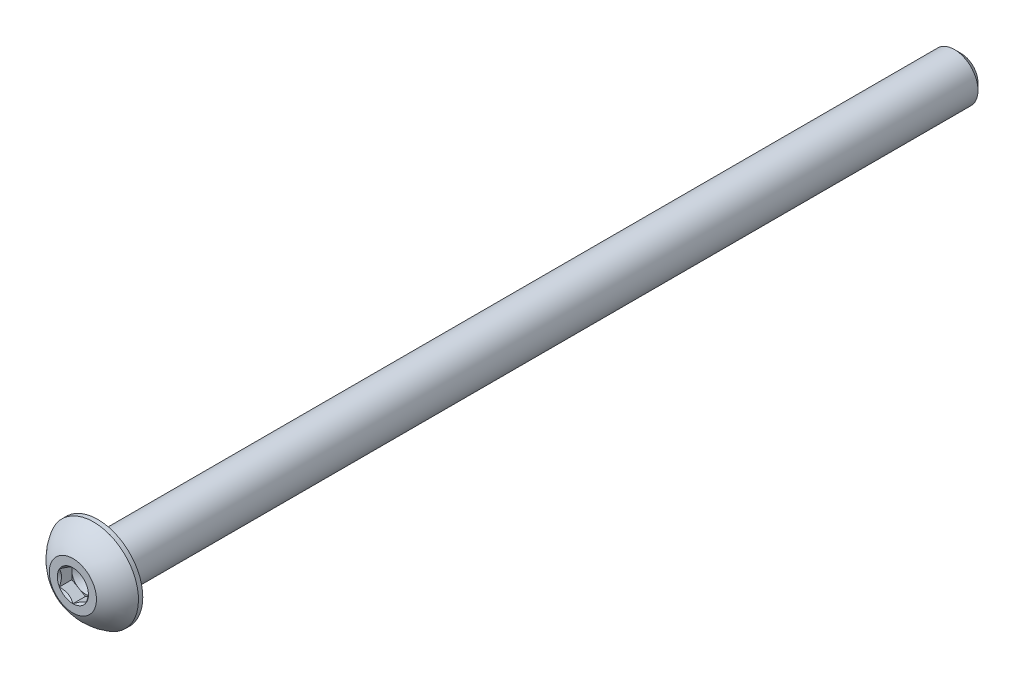
from build123d import *

# Parameters (mm, degrees)
SKETCH1_W          = 76.2
SKETCH1_H          = 2.0828
CHAMFER1_SIZE      = 0.5953125
SKETCH4_R          = 3.9624
EXTRUDE1_DEPTH     = 2.2098
CUT_EXTRUDE1_DEPTH = 1.1049
SKETCH7_R          = 1.374815329
CUT_EXTRUDE4_DEPTH = 1.1049
CUT_EXTRUDE4_TAPER = 45
SKETCH8_R          = 1.190625
CUT_EXTRUDE5_DEPTH = 0.3683
CUT_EXTRUDE5_TAPER = 60


with BuildPart() as part:
    # Sketch1 → Revolve1 (revolve)
    with BuildSketch(Plane(origin=(0, 0, 0), x_dir=(0, 0, -1), z_dir=(1, 0, 0))):
        with Locations((38.1, 1.0414)):
            Rectangle(SKETCH1_W, SKETCH1_H)
    revolve(axis=Axis((0, 0, 0), (0, 0, 1)))

    # Chamfer1
    chamfer1_edges = [part.edges().sort_by_distance(p)[0] for p in [
        (0, -2.0828, -76.2),
    ]]
    chamfer(chamfer1_edges, length=CHAMFER1_SIZE)

    # Sketch4 → Extrude1 (add)
    with BuildSketch(Plane.XY):
        Circle(SKETCH4_R)
    extrude(amount=EXTRUDE1_DEPTH)

    # Sketch9 → Cut-Revolve3 (revolve, cut)
    with BuildSketch(Plane(origin=(0, 0, 0), x_dir=(0, 0, -1), z_dir=(1, 0, 0))):
        with BuildLine():
            Line((0, 3.9624), (-0.381, 3.9624))
            ThreePointArc((-0.381, 3.9624), (-1.434442989, 3.157885071), (-2.2098, 2.0828))
            Line((-2.2098, 2.0828), (-2.5908, 2.0828))
            Line((-2.5908, 2.0828), (-2.5908, 4.3434))
            Line((-2.5908, 4.3434), (0, 4.3434))
            Line((0, 4.3434), (0, 3.9624))
        make_face()
    revolve(axis=Axis((0, 0, 0), (0, 0, 1)), mode=Mode.SUBTRACT)

    # Sketch6 → Cut-Extrude1 (cut)
    with BuildSketch(Plane.XY.offset(2.2098)):
        Polygon((0, -1.374815329), (1.190625, -0.687407664), (1.190625, 0.687407664), (0, 1.374815329), (-1.190625, 0.687407664), (-1.190625, -0.687407664), align=None)
    extrude(amount=-CUT_EXTRUDE1_DEPTH, mode=Mode.SUBTRACT)

    # Sketch7 → Cut-Extrude4 (cut)
    with BuildSketch(Plane.XY.offset(2.2098)):
        Circle(SKETCH7_R)
    extrude(amount=-CUT_EXTRUDE4_DEPTH, taper=CUT_EXTRUDE4_TAPER, mode=Mode.SUBTRACT)

    # Sketch8 → Cut-Extrude5 (cut)
    with BuildSketch(Plane.XY.offset(1.1049)):
        Circle(SKETCH8_R)
    extrude(amount=-CUT_EXTRUDE5_DEPTH, taper=CUT_EXTRUDE5_TAPER, mode=Mode.SUBTRACT)


solid = part.part
